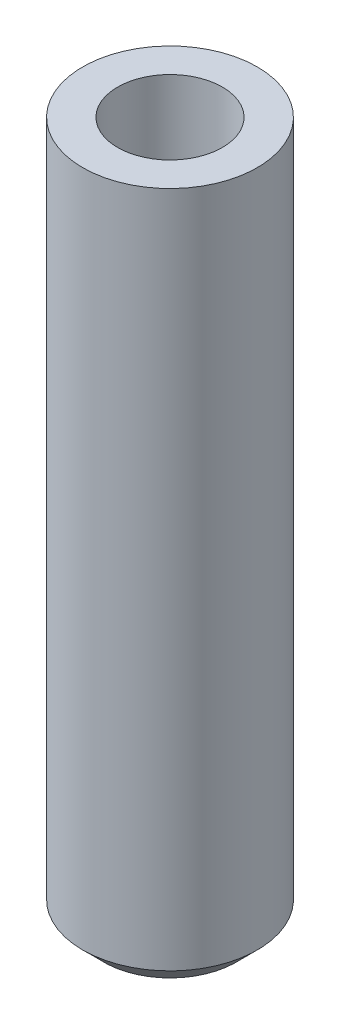
from build123d import *

# Parameters (mm, degrees)
SKETCH1_W     = 2
SKETCH1_H     = 40
CHAMFER1_SIZE = 1.2


with BuildPart() as part:
    # Sketch1 → Revolve1 (revolve)
    with BuildSketch(Plane.XY):
        with Locations((4, 20)):
            Rectangle(SKETCH1_W, SKETCH1_H)
    revolve(axis=Axis((0, 0, 0), (0, 1, 0)))

    # Chamfer1
    chamfer1_edges = [part.edges().sort_by_distance(p)[0] for p in [
        (-5, 0, 0),
    ]]
    chamfer(chamfer1_edges, length=CHAMFER1_SIZE)


solid = part.part
